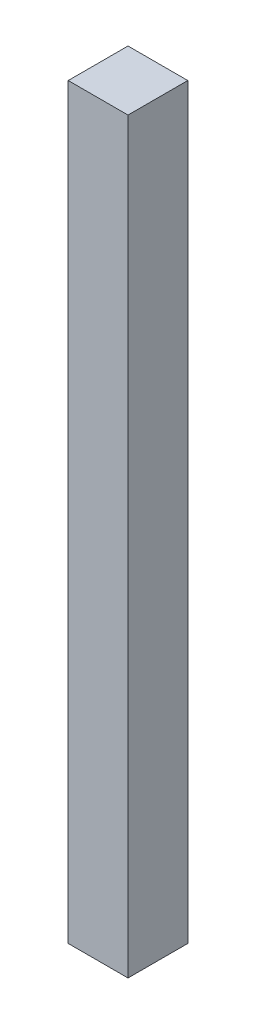
from build123d import *

# Parameters (mm, degrees)
SKETCH1_W           = 40
SKETCH1_H           = 500
BOSS_EXTRUDE1_DEPTH = 40


with BuildPart() as part:
    # Sketch1 → Boss-Extrude1 (new body)
    with BuildSketch(Plane.XY):
        Rectangle(SKETCH1_W, SKETCH1_H)
    extrude(amount=BOSS_EXTRUDE1_DEPTH)


solid = part.part
